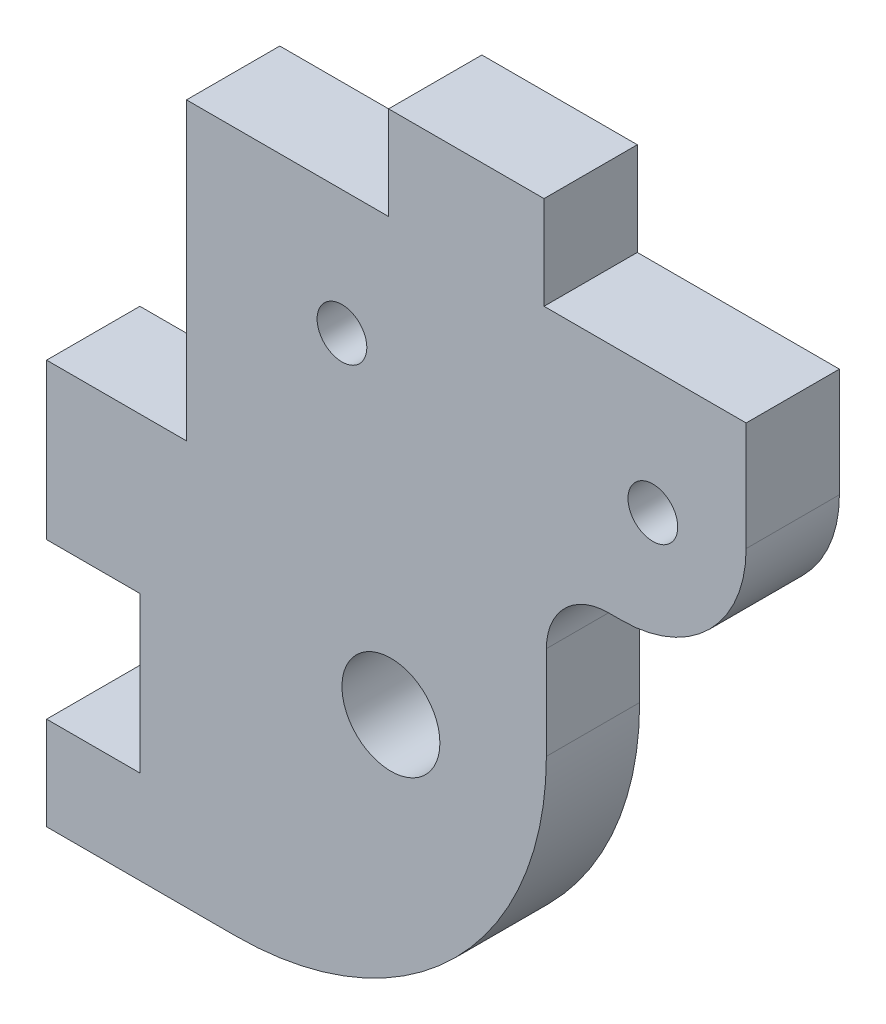
from build123d import *

# Parameters (mm, degrees)
ESBO_O1_R                = 3.15
ESBO_O1_R_2              = 1.6
RESSALTO_EXTRUS_O1_DEPTH = 6
FILETE2_R                = 8
FILETE3_R                = 4
FILETE4_R                = 20


with BuildPart() as part:
    # Esboço1 → Ressalto-extrusão1 (new body)
    with BuildSketch(Plane.XY):
        Polygon((22, 0), (9, 0), (9, -19), (0, -19), (0, -29), (6, -29), (6, -39), (0, -39), (0, -45), (32.15, -45), (32.15, -15), (45, -15), (45, 0), (32, 0), (32, 6), (22, 6), align=None)
        with Locations((22.15, -27.680849585)):
            Circle(ESBO_O1_R, mode=Mode.SUBTRACT)
        with Locations((19, -8)):
            Circle(ESBO_O1_R_2, mode=Mode.SUBTRACT)
        with Locations((39, -8)):
            Circle(ESBO_O1_R_2, mode=Mode.SUBTRACT)
    extrude(amount=RESSALTO_EXTRUS_O1_DEPTH)

    # Filete2
    filete2_edges = [part.edges().sort_by_distance(p)[0] for p in [
        (45, -15, 3),
    ]]
    fillet(filete2_edges, radius=FILETE2_R)

    # Filete3
    filete3_edges = [part.edges().sort_by_distance(p)[0] for p in [
        (32.15, -15, 3),
    ]]
    fillet(filete3_edges, radius=FILETE3_R)

    # Filete4
    filete4_edges = [part.edges().sort_by_distance(p)[0] for p in [
        (32.15, -45, 3),
    ]]
    fillet(filete4_edges, radius=FILETE4_R)


solid = part.part
